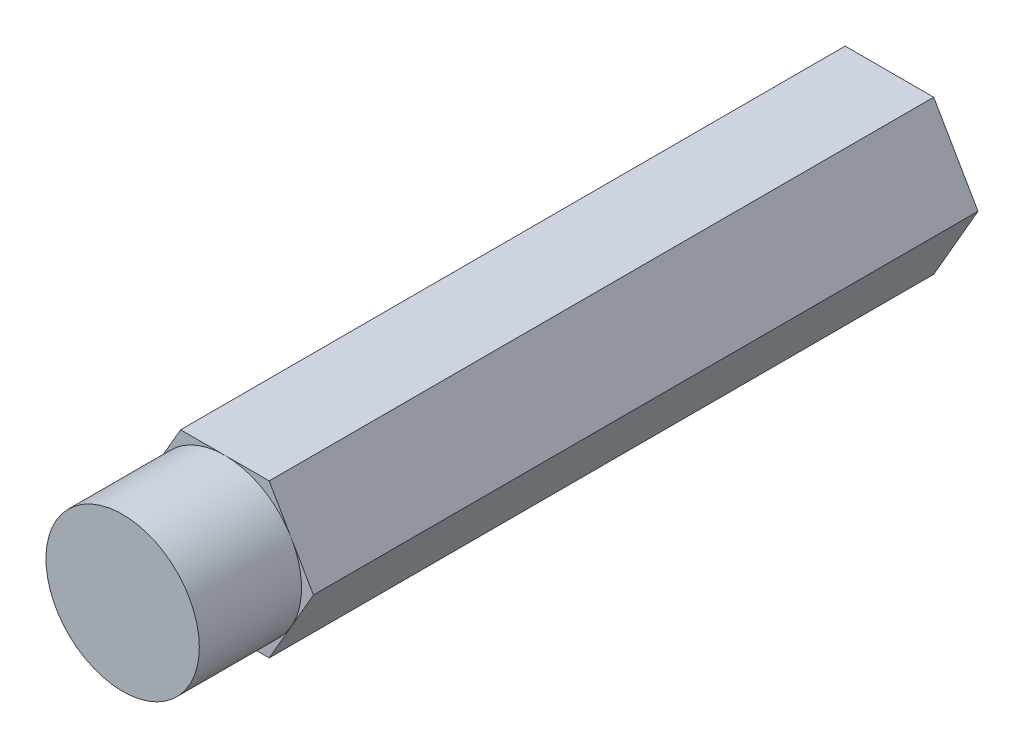
from build123d import *

# Parameters (mm, degrees)
BOSS_EXTRUDE1_DEPTH = 41.275
SKETCH2_R           = 4.7625
BOSS_EXTRUDE2_DEPTH = 6.35


with BuildPart() as part:
    # Sketch1 → Boss-Extrude1 (new body)
    with BuildSketch(Plane.XY):
        Polygon((-2.749630657, -4.7625), (2.749630657, -4.7625), (5.499261314, 0), (2.749630657, 4.7625), (-2.749630657, 4.7625), (-5.499261314, 0), align=None)
    extrude(amount=BOSS_EXTRUDE1_DEPTH)

    # Sketch2 → Boss-Extrude2 (add)
    with BuildSketch(Plane.XY.offset(41.275)):
        with Locations(Location((0, 0, 0), (0, 0, 150))):  # turned: the seam where the file's is
            Circle(SKETCH2_R)
    extrude(amount=BOSS_EXTRUDE2_DEPTH)


solid = part.part
